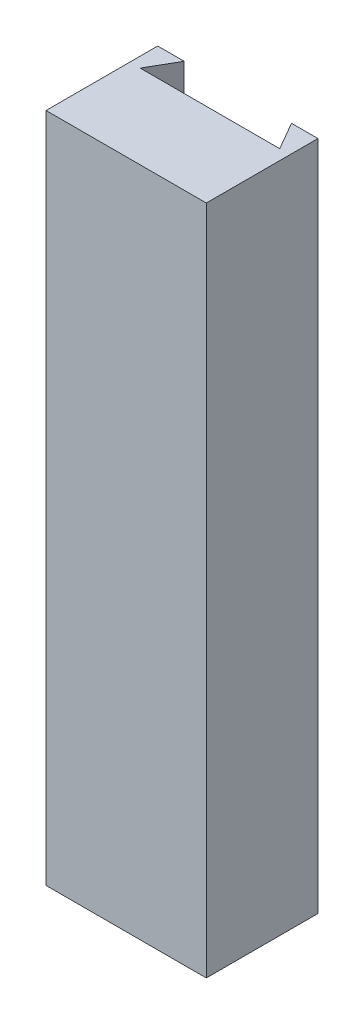
from build123d import *

# Parameters (mm, degrees)
SKETCH1_W           = 2.87
SKETCH1_H           = 12.02
BOSS_EXTRUDE1_DEPTH = 2
CUT_EXTRUDE1_REACH  = 14.02


with BuildPart() as part:
    # Sketch1 → Boss-Extrude1 (new body)
    with BuildSketch(Plane.XY):
        with Locations((0, 6.01)):
            Rectangle(SKETCH1_W, SKETCH1_H)
    extrude(amount=BOSS_EXTRUDE1_DEPTH)

    # Sketch2 → Cut-Extrude1 (cut, up to next)
    with BuildSketch(Plane.XZ, mode=Mode.PRIVATE) as cut_extrude1_sk1:
        Polygon((0, -1.665063509), (1.25, 0.5), (-1.25, 0.5), align=None)
    cut_extrude1_tool1 = extrude(cut_extrude1_sk1.sketch, amount=-CUT_EXTRUDE1_REACH, mode=Mode.PRIVATE) & part.part
    add(cut_extrude1_tool1.solids().sort_by_distance((0, 0, -0.221688))[0], mode=Mode.SUBTRACT)


solid = part.part
